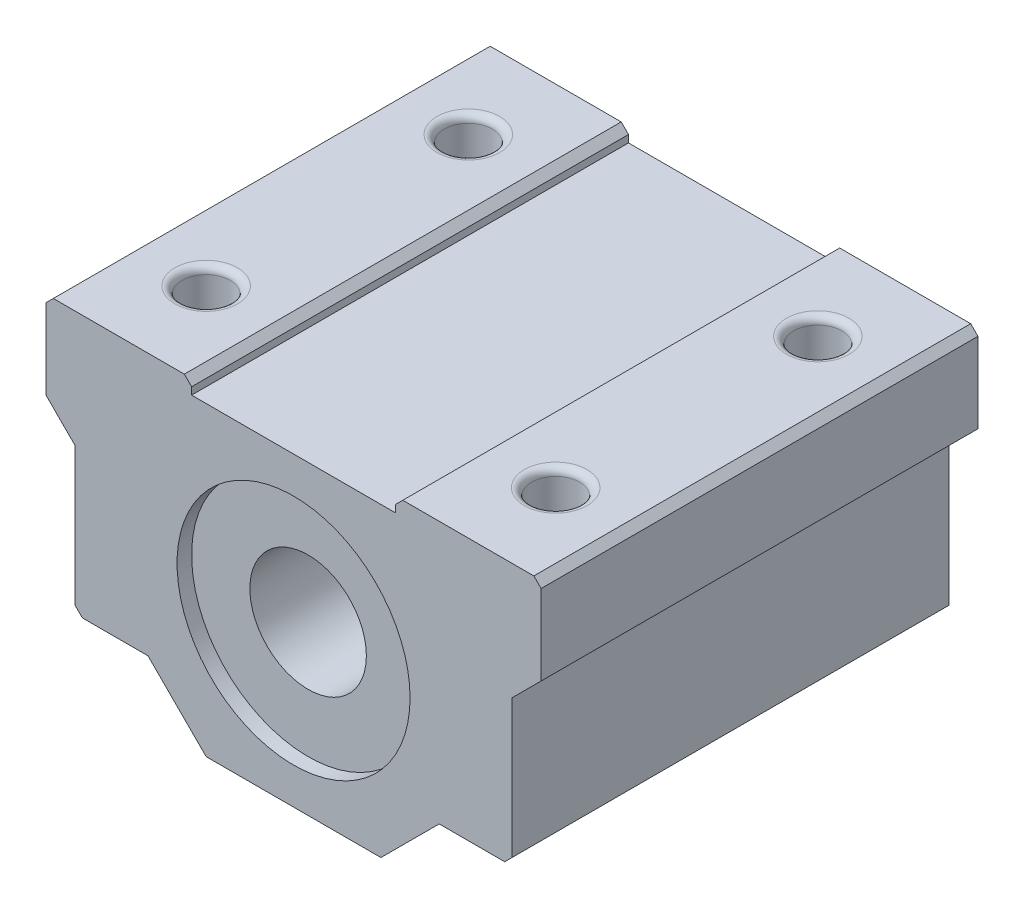
from build123d import *

# Parameters (mm, degrees)
SKETCH1_R           = 8
BOSS_EXTRUDE1_DEPTH = 15
SKETCH2_R           = 1.65
CUT_EXTRUDE1_DEPTH  = 23
SKETCH3_R           = 8
SKETCH3_R_2         = 4
BOSS_EXTRUDE2_DEPTH = 14
FILLET1_R           = 0.5
CHAMFER1_SIZE       = 0.5


with BuildPart() as part:
    # Sketch1 → Boss-Extrude1 (new body, symmetric)
    with BuildSketch(Plane.XY):
        Polygon((-17, 11.5), (-7, 11.5), (-7, 10.5), (7, 10.5), (7, 11.5), (17, 11.5), (17, 5.5), (15, 3.5), (15, -6.5), (10, -6.5), (6, -10.5), (-6, -10.5), (-10, -6.5), (-15, -6.5), (-15, 3.5), (-17, 5.5), align=None)
        Circle(SKETCH1_R, mode=Mode.SUBTRACT)
    extrude(amount=BOSS_EXTRUDE1_DEPTH, both=True)

    # Sketch2 → Cut-Extrude1 (cut, through all)
    with BuildSketch(Plane(origin=(0, 11.5, 0), x_dir=(1, 0, 0), z_dir=(0, 1, 0))):
        with Locations((-12, 9)):
            Circle(SKETCH2_R)
        with Locations((-12, -9)):
            Circle(SKETCH2_R)
        with Locations((12, -9)):
            Circle(SKETCH2_R)
        with Locations((12, 9)):
            Circle(SKETCH2_R)
    extrude(amount=-CUT_EXTRUDE1_DEPTH, mode=Mode.SUBTRACT)

    # Sketch3 → Boss-Extrude2 (add, symmetric)
    with BuildSketch(Plane.XY):
        Circle(SKETCH3_R)
        Circle(SKETCH3_R_2, mode=Mode.SUBTRACT)
    extrude(amount=BOSS_EXTRUDE2_DEPTH, both=True)

    # Fillet1
    fillet1_edges = [part.edges().sort_by_distance(p)[0] for p in [
        (-13.65, 11.5, -9),
        (-13.65, 11.5, 9),
        (10.35, 11.5, 9),
        (10.35, 11.5, -9),
    ]]
    fillet(fillet1_edges, radius=FILLET1_R)

    # Chamfer1
    chamfer1_edges = [part.edges().sort_by_distance(p)[0] for p in [
        (-17, 11.5, 0),
        (-7, 11.5, 0),
        (7, 11.5, 0),
        (17, 11.5, 0),
        (15, -6.5, 0),
        (-15, -6.5, 0),
    ]]
    chamfer(chamfer1_edges, length=CHAMFER1_SIZE)


solid = part.part
